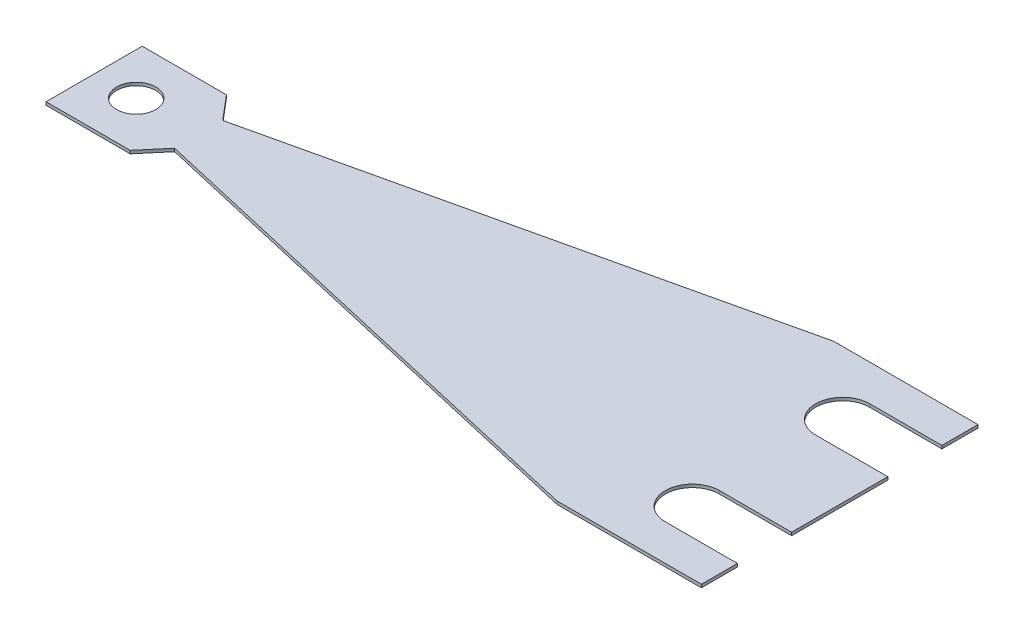
from build123d import *

# Parameters (mm, degrees)
EXTRUDE1_DEPTH = 0.254
EXTRUDE2_DEPTH = 1.254
SKETCH3_R      = 1.63
EXTRUDE3_DEPTH = 1.254


with BuildPart() as part:
    # Sketch1 → Extrude1 (new body)
    with BuildSketch(Plane(origin=(0, 0, 0), x_dir=(1, 0, 0), z_dir=(0, 1, 0))):
        Polygon((0, -11.5), (0, 11.5), (-12, 11.5), (-53.304347826, 2), (-55, 4), (-62, 4), (-62, -4), (-55, -4), (-53.304347826, -2), (-12, -11.5), align=None)
    extrude(amount=EXTRUDE1_DEPTH)

    # Sketch2 → Extrude2 (cut, through all)
    with BuildSketch(Plane(origin=(0, 0.254, 0), x_dir=(1, 0, 0), z_dir=(0, 1, 0))):
        with BuildLine():
            Line((-6, 4), (0, 4))
            Line((0, 4), (0, 8.5))
            Line((0, 8.5), (-6, 8.5))
            ThreePointArc((-6, 8.5), (-8.25, 6.25), (-6, 4))
        make_face()
        with BuildLine():
            Line((0, -8.5), (-6, -8.5))
            ThreePointArc((-6, -8.5), (-8.25, -6.25), (-6, -4))
            Line((-6, -4), (0, -4))
            Line((0, -4), (0, -8.5))
        make_face()
    extrude(amount=-EXTRUDE2_DEPTH, mode=Mode.SUBTRACT)

    # Sketch3 → Extrude3 (cut, through all)
    with BuildSketch(Plane(origin=(0, 0.254, 0), x_dir=(1, 0, 0), z_dir=(0, 1, 0))):
        with Locations(Location((-58.5, 0, 0), (0, 0, 270))):  # turned: the seam where the file's is
            Circle(SKETCH3_R)
    extrude(amount=-EXTRUDE3_DEPTH, mode=Mode.SUBTRACT)


solid = part.part
